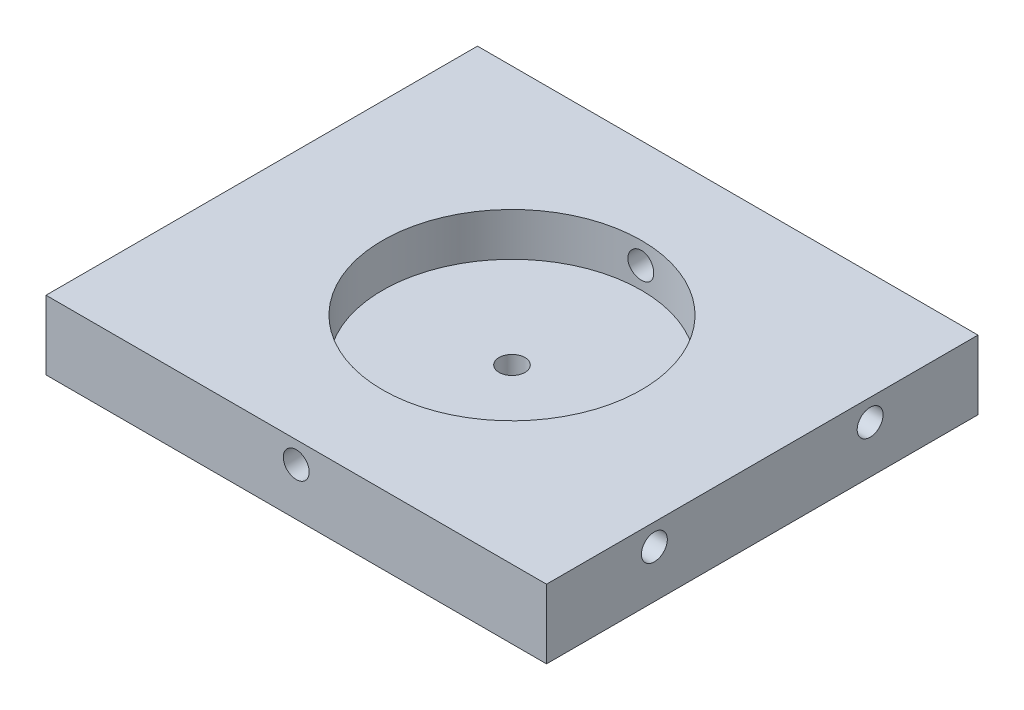
from build123d import *

# Parameters (mm, degrees)
ESQUISSE1_W             = 58
ESQUISSE1_H             = 8
BOSS_EXTRU_1_DEPTH      = 50
ESQUISSE2_R             = 15
ENL_V_MAT_EXTRU_1_DEPTH = 5
ESQUISSE3_R             = 1.5
ENL_V_MAT_EXTRU_2_DEPTH = 10
ESQUISSE4_R             = 1.5
ENL_V_MAT_EXTRU_3_DEPTH = 10
ESQUISSE5_R             = 1.5
ENL_V_MAT_EXTRU_4_DEPTH = 4
ESQUISSE6_R             = 1.5
ENL_V_MAT_EXTRU_5_DEPTH = 51


with BuildPart() as part:
    # Esquisse1 → Boss.-Extru.1 (new body)
    with BuildSketch(Plane.XY):
        with Locations((23.5, -49)):
            Rectangle(ESQUISSE1_W, ESQUISSE1_H)
    extrude(amount=BOSS_EXTRU_1_DEPTH)

    # Esquisse2 → Enlèv. mat.-Extru.1 (cut)
    with BuildSketch(Plane(origin=(0, -45, 0), x_dir=(-1, 0, 0), z_dir=(0, 1, 0))):
        with Locations((-23.5, 25)):
            Circle(ESQUISSE2_R)
    extrude(amount=-ENL_V_MAT_EXTRU_1_DEPTH, mode=Mode.SUBTRACT)

    # Esquisse3 → Enlèv. mat.-Extru.2 (cut)
    with BuildSketch(Plane.ZY.offset(5.5)):
        with Locations((12.5, -47.5)):
            Circle(ESQUISSE3_R)
        with Locations((37.5, -47.5)):
            Circle(ESQUISSE3_R)
    extrude(amount=-ENL_V_MAT_EXTRU_2_DEPTH, mode=Mode.SUBTRACT)

    # Esquisse4 → Enlèv. mat.-Extru.3 (cut)
    with BuildSketch(Plane(origin=(52.5, 0, 0), x_dir=(0, 0, -1), z_dir=(1, 0, 0))):
        with Locations((-37.5, -47.5)):
            Circle(ESQUISSE4_R)
        with Locations((-12.5, -47.5)):
            Circle(ESQUISSE4_R)
    extrude(amount=-ENL_V_MAT_EXTRU_3_DEPTH, mode=Mode.SUBTRACT)

    # Esquisse5 → Enlèv. mat.-Extru.4 (cut, through all)
    with BuildSketch(Plane(origin=(0, -50, 0), x_dir=(1, 0, 0), z_dir=(0, 1, 0))):
        with Locations((23.5, -25)):
            Circle(ESQUISSE5_R)
    extrude(amount=-ENL_V_MAT_EXTRU_4_DEPTH, mode=Mode.SUBTRACT)

    # Esquisse6 → Enlèv. mat.-Extru.5 (cut, through all)
    with BuildSketch(Plane(origin=(0, 0, 0), x_dir=(-1, 0, 0), z_dir=(0, 0, -1))):
        with Locations((-23.5, -47.5)):
            Circle(ESQUISSE6_R)
    extrude(amount=-ENL_V_MAT_EXTRU_5_DEPTH, mode=Mode.SUBTRACT)


solid = part.part
